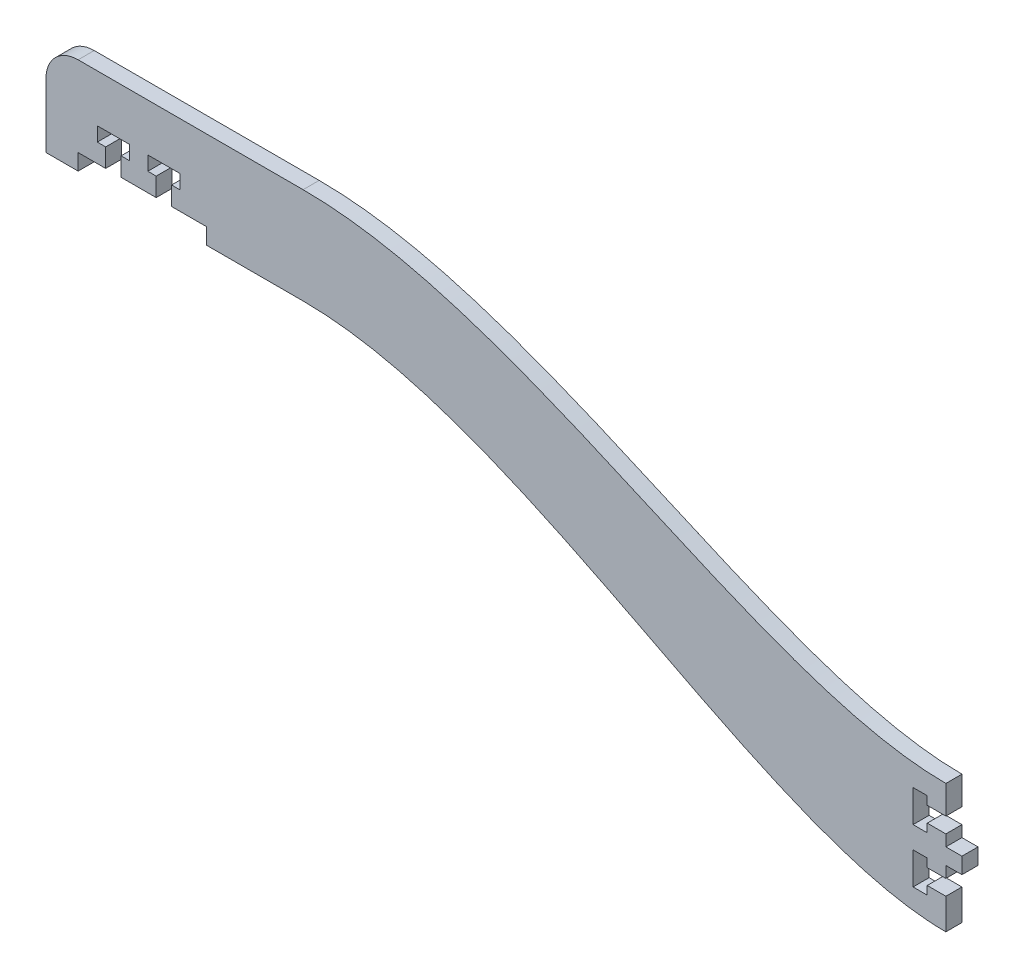
from build123d import *

# Parameters (mm, degrees)
BOSS_EXTRUDE1_DEPTH = 3.175


with BuildPart() as part:
    # Sketch1 → Boss-Extrude1 (new body)
    with BuildSketch(Plane.XY):
        with BuildLine():
            Line((-50.8, 12.7), (-50.8, 0))
            Line((-50.8, 0), (-44.45, 0))
            Line((-44.45, 0), (-44.45, 3.175))
            Line((-44.45, 3.175), (-39.0144, 3.175))
            Line((-39.0144, 3.175), (-39.0144, 6.858))
            Line((-39.0144, 6.858), (-40.6654, 6.858))
            Line((-40.6654, 6.858), (-40.6654, 9.652))
            Line((-40.6654, 9.652), (-34.3154, 9.652))
            Line((-34.3154, 9.652), (-34.3154, 6.858))
            Line((-34.3154, 6.858), (-35.9664, 6.858))
            Line((-35.9664, 6.858), (-35.9664, 3.175))
            Line((-35.9664, 3.175), (-29.0322, 3.175))
            Line((-29.0322, 3.175), (-29.0322, 6.858))
            Line((-29.0322, 6.858), (-30.6832, 6.858))
            Line((-30.6832, 6.858), (-30.6832, 9.652))
            Line((-30.6832, 9.652), (-24.3332, 9.652))
            Line((-24.3332, 9.652), (-24.3332, 6.858))
            Line((-24.3332, 6.858), (-25.9842, 6.858))
            Line((-25.9842, 6.858), (-25.9842, 3.175))
            Line((-25.9842, 3.175), (-19.05, 3.175))
            Line((-19.05, 3.175), (-19.05, 0))
            Line((-19.05, 0), (0, 0))
            add(Edge.make_bspline(
                [(0, 0), (43.75699028, 0), (90.568040393, -44.45), (127, -44.45)],
                knots=[0, 0, 0, 0, 1, 1, 1, 1], degree=3))
            Line((127, -44.45), (127, -38.354))
            Line((127, -38.354), (123.317, -38.354))
            Line((123.317, -38.354), (123.317, -40.005))
            Line((123.317, -40.005), (120.523, -40.005))
            Line((120.523, -40.005), (120.523, -33.655))
            Line((120.523, -33.655), (123.317, -33.655))
            Line((123.317, -33.655), (123.317, -35.306))
            Line((123.317, -35.306), (127, -35.306))
            Line((127, -35.306), (127, -33.0835))
            Line((127, -33.0835), (130.175, -33.0835))
            Line((130.175, -33.0835), (130.175, -29.9085))
            Line((130.175, -29.9085), (127, -29.9085))
            Line((127, -29.9085), (127, -27.686))
            Line((127, -27.686), (123.317, -27.686))
            Line((123.317, -27.686), (123.317, -29.337))
            Line((123.317, -29.337), (120.523, -29.337))
            Line((120.523, -29.337), (120.523, -22.987))
            Line((120.523, -22.987), (123.317, -22.987))
            Line((123.317, -22.987), (123.317, -24.638))
            Line((123.317, -24.638), (127, -24.638))
            Line((127, -24.638), (127, -19.05))
            add(Edge.make_bspline(
                [(0, 19.05), (43.75699028, 19.05), (89.987535232, -19.05), (127, -19.05)],
                knots=[0, 0, 0, 0, 1, 1, 1, 1], degree=3))
            Line((0, 19.05), (-44.45, 19.05))
            ThreePointArc((-44.45, 19.05), (-48.940128061, 17.190128061), (-50.8, 12.7))
        make_face()
    extrude(amount=BOSS_EXTRUDE1_DEPTH)


solid = part.part
